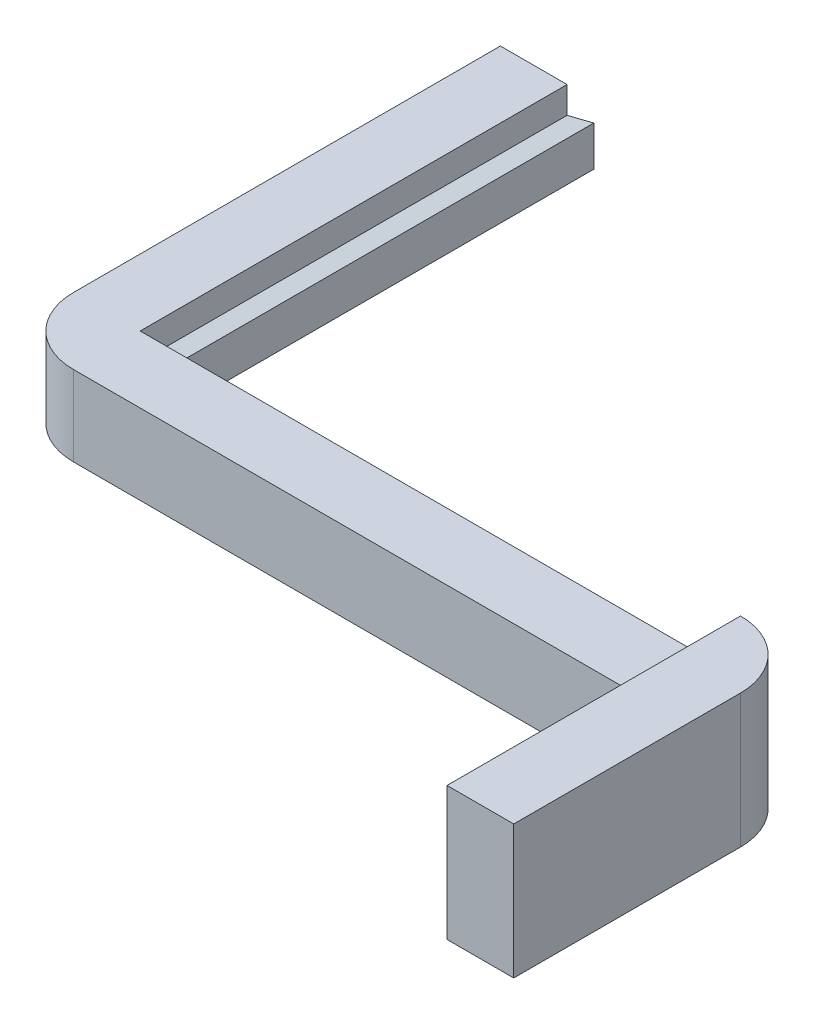
from build123d import *

# Parameters (mm, degrees)
SKETCH1_W           = 45
SKETCH1_H           = 6
BOSS_EXTRUDE1_DEPTH = 5
SKETCH2_W           = 37
SKETCH2_H           = 6
BOSS_EXTRUDE2_DEPTH = 5
FILLET1_R           = 5
SKETCH3_W           = 22
SKETCH3_H           = 10
BOSS_EXTRUDE3_DEPTH = 5
FILLET2_R           = 5
BOSS_EXTRUDE4_DEPTH = 32


with BuildPart() as part:
    # Sketch1 → Boss-Extrude1 (new body)
    with BuildSketch(Plane.XY):
        Rectangle(SKETCH1_W, SKETCH1_H)
    extrude(amount=BOSS_EXTRUDE1_DEPTH)

    # Sketch2 → Boss-Extrude2 (add)
    with BuildSketch(Plane.ZY.offset(22.5)):
        with Locations((-13.5, 0)):
            Rectangle(SKETCH2_W, SKETCH2_H)
    extrude(amount=BOSS_EXTRUDE2_DEPTH)

    # Fillet1
    fillet1_edges = [part.edges().sort_by_distance(p)[0] for p in [
        (-27.5, 0, 5),
    ]]
    fillet(fillet1_edges, radius=FILLET1_R)

    # Sketch3 → Boss-Extrude3 (add)
    with BuildSketch(Plane(origin=(22.5, 0, 0), x_dir=(0, 0, -1), z_dir=(1, 0, 0))):
        with Locations((-11, 2)):
            Rectangle(SKETCH3_W, SKETCH3_H)
    extrude(amount=BOSS_EXTRUDE3_DEPTH)

    # Fillet2
    fillet2_edges = [part.edges().sort_by_distance(p)[0] for p in [
        (27.5, 2, 0),
    ]]
    fillet(fillet2_edges, radius=FILLET2_R)

    # Sketch5 → Boss-Extrude4 (add)
    with BuildSketch(Plane(origin=(0, 0, 0), x_dir=(-1, 0, 0), z_dir=(0, 0, -1))):
        Polygon((22.5, 1), (20.5, 1.5), (20.5, -1.5), (22.5, -1), align=None)
    extrude(amount=BOSS_EXTRUDE4_DEPTH)


solid = part.part
